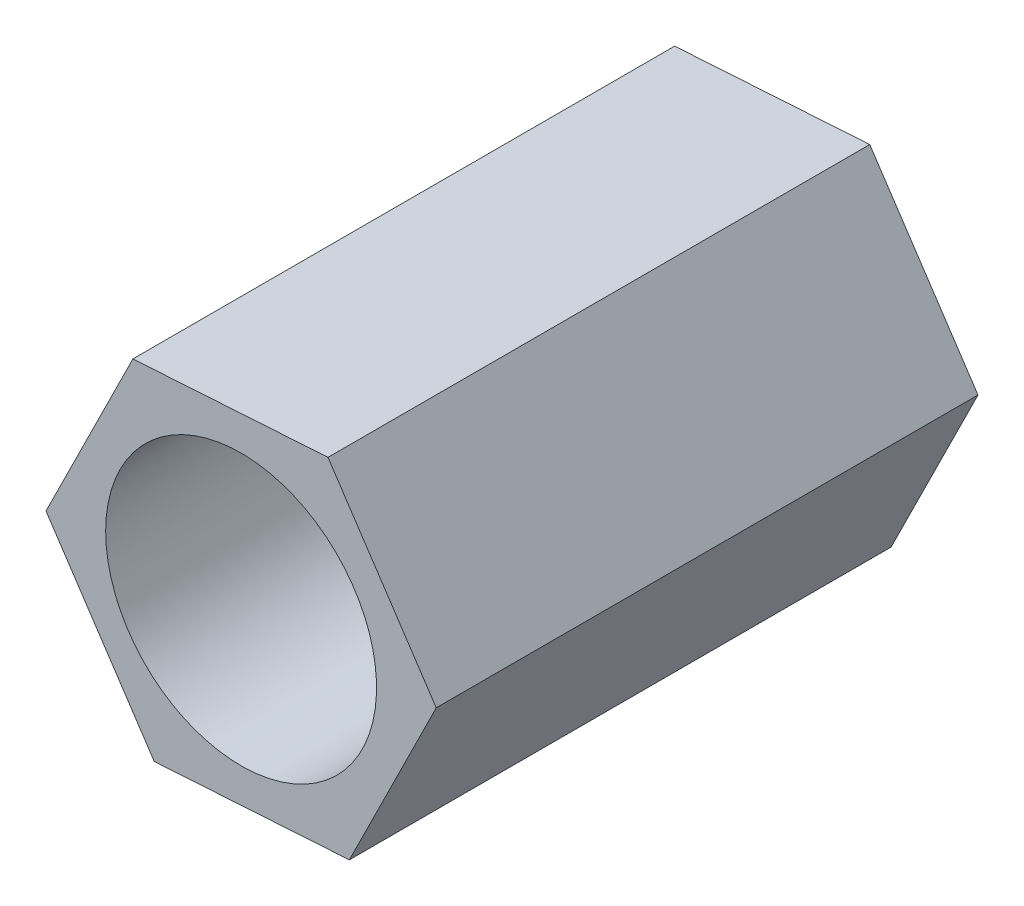
from build123d import *

# Parameters (mm, degrees)
EXTRUDE_1_DEPTH     = 8
SKETCH_2_R          = 2
CUT_EXTRUDE_1_DEPTH = 9


with BuildPart() as part:
    # 草图1 → 凸台-拉伸1 (new body)
    with BuildSketch(Plane.XY):
        Polygon((1.28284299, 2.586048568), (-1.59816226, 2.403998903), (-2.88100525, -0.182049665), (-1.28284299, -2.586048568), (1.59816226, -2.403998903), (2.88100525, 0.182049665), align=None)
    extrude(amount=EXTRUDE_1_DEPTH)

    # 草图2 → 切除-拉伸1 (cut, through all)
    with BuildSketch(Plane(origin=(0, 0, 0), x_dir=(-1, 0, 0), z_dir=(0, 0, -1))):
        Circle(SKETCH_2_R)
    extrude(amount=-CUT_EXTRUDE_1_DEPTH, mode=Mode.SUBTRACT)


solid = part.part
